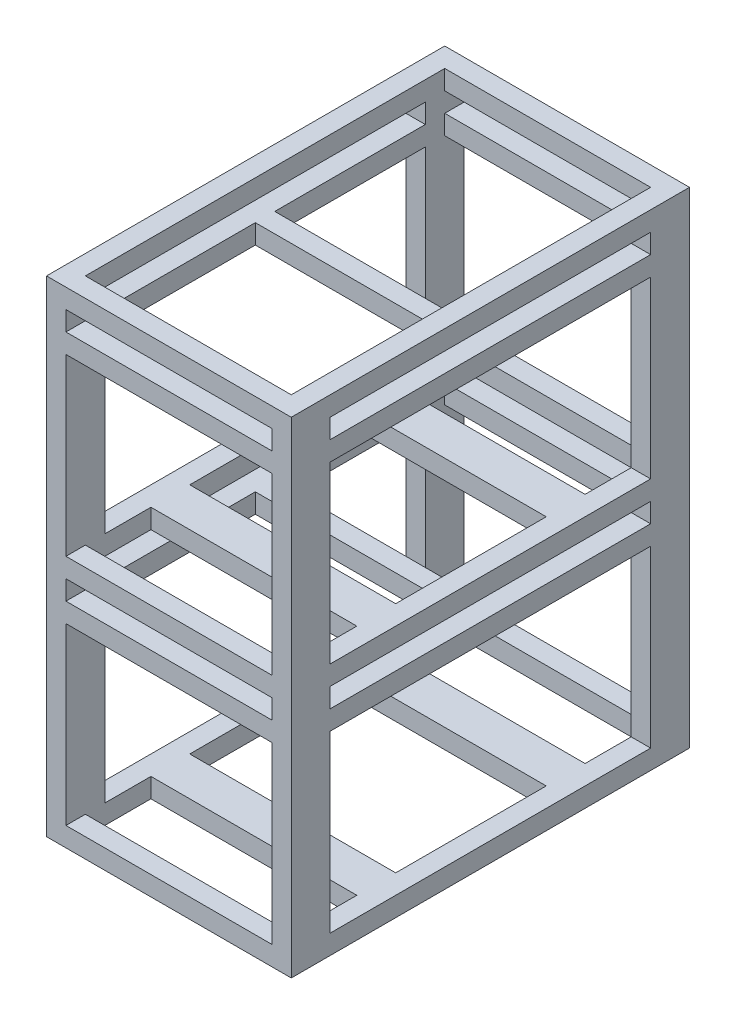
from build123d import *

# Parameters (mm, degrees)
SKETCH1_W           = 252
SKETCH1_H           = 410
SKETCH1_W_2         = 212
SKETCH1_H_2         = 370
BOSS_EXTRUDE1_DEPTH = 20
SKETCH2_W           = 20
SKETCH2_H           = 40
BOSS_EXTRUDE2_DEPTH = 460
BOSS_EXTRUDE3_START = 460
SKETCH1_3_W         = 252
SKETCH1_3_H         = 410
SKETCH1_3_W_2       = 212
SKETCH1_3_H_2       = 370
BOSS_EXTRUDE3_DEPTH = 20
SKETCH3_W           = 212
SKETCH3_H           = 40
BOSS_EXTRUDE4_DEPTH = 20
SKETCH4_W           = 20
SKETCH4_H           = 20
BOSS_EXTRUDE5_DEPTH = 330
SKETCH6_W           = 20
SKETCH6_H           = 20
BOSS_EXTRUDE6_DEPTH = 212
LPATTERN2_COUNT     = 2
LPATTERN2_PITCH     = 240
LPATTERN1_COUNT     = 2
LPATTERN1_PITCH     = 240
LPATTERN3_COUNT     = 2
LPATTERN3_PITCH     = 240


with BuildPart() as part:
    # Sketch1 → Boss-Extrude1 (new body)
    with BuildSketch(Plane(origin=(0, 0, 0), x_dir=(1, 0, 0), z_dir=(0, 1, 0))):
        Rectangle(SKETCH1_W, SKETCH1_H)
        Rectangle(SKETCH1_W_2, SKETCH1_H_2, mode=Mode.SUBTRACT)
    boss_extrude1 = extrude(amount=-BOSS_EXTRUDE1_DEPTH)

    # Sketch2 → Boss-Extrude2 (add)
    with BuildSketch(Plane(origin=(0, 0, 0), x_dir=(1, 0, 0), z_dir=(0, 1, 0))):
        with Locations((-116, 185)):
            Rectangle(SKETCH2_W, SKETCH2_H)
        with Locations((-116, -185)):
            Rectangle(SKETCH2_W, SKETCH2_H)
        with Locations((116, -185)):
            Rectangle(SKETCH2_W, SKETCH2_H)
        with Locations((116, 185)):
            Rectangle(SKETCH2_W, SKETCH2_H)
    extrude(amount=BOSS_EXTRUDE2_DEPTH)

    # Sketch1_3 → Boss-Extrude3 (add)
    with BuildSketch(Plane(origin=(0, 0, 0), x_dir=(1, 0, 0), z_dir=(0, 1, 0)).offset(BOSS_EXTRUDE3_START)):
        Rectangle(SKETCH1_3_W, SKETCH1_3_H)
        Rectangle(SKETCH1_3_W_2, SKETCH1_3_H_2, mode=Mode.SUBTRACT)
    extrude(amount=BOSS_EXTRUDE3_DEPTH)

    # Sketch3 → Boss-Extrude4 (add)
    with BuildSketch(Plane(origin=(0, 0, 0), x_dir=(1, 0, 0), z_dir=(0, 1, 0))):
        with Locations((0, -97.5)):
            Rectangle(SKETCH3_W, SKETCH3_H)
        with Locations((0, 97.5)):
            Rectangle(SKETCH3_W, SKETCH3_H)
    boss_extrude4 = extrude(amount=-BOSS_EXTRUDE4_DEPTH)

    # Sketch4 → Boss-Extrude5 (add)
    with BuildSketch(Plane(origin=(0, 0, 165), x_dir=(-1, 0, 0), z_dir=(0, 0, -1))):
        with Locations((-116, 190)):
            Rectangle(SKETCH4_W, SKETCH4_H)
        with Locations((116, 190)):
            Rectangle(SKETCH4_W, SKETCH4_H)
    boss_extrude5 = extrude(amount=BOSS_EXTRUDE5_DEPTH)

    # Sketch6 → Boss-Extrude6 (add)
    with BuildSketch(Plane.ZY.offset(-106)):
        with Locations((-195, 190)):
            Rectangle(SKETCH6_W, SKETCH6_H)
        with Locations((0, 190)):
            Rectangle(SKETCH6_W, SKETCH6_H)
        with Locations((195, 190)):
            Rectangle(SKETCH6_W, SKETCH6_H)
    boss_extrude6 = extrude(amount=BOSS_EXTRUDE6_DEPTH)

    # LPattern2: Boss-Extrude5 ×2
    with Locations(*[(0, i * LPATTERN2_PITCH, 0) for i in range(1, LPATTERN2_COUNT)]):
        add(boss_extrude5)

    # LPattern1: Boss-Extrude6 ×2
    with Locations(*[(0, i * LPATTERN1_PITCH, 0) for i in range(1, LPATTERN1_COUNT)]):
        add(boss_extrude6)

    # LPattern3: Boss-Extrude1, Boss-Extrude4 ×2
    with Locations(*[(0, i * LPATTERN3_PITCH, 0) for i in range(1, LPATTERN3_COUNT)]):
        add(boss_extrude1)
        add(boss_extrude4)


solid = part.part
